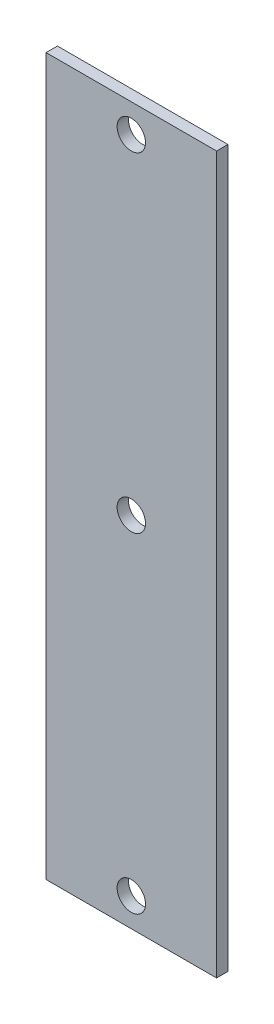
from build123d import *

# Parameters (mm, degrees)
SKETCH1_W           = 30
SKETCH1_H           = 126
SKETCH1_R           = 2.5
BOSS_EXTRUDE1_DEPTH = 2


with BuildPart() as part:
    # Sketch1 → Boss-Extrude1 (new body)
    with BuildSketch(Plane.XY):
        Rectangle(SKETCH1_W, SKETCH1_H)
        with Locations((0, 58)):
            Circle(SKETCH1_R, mode=Mode.SUBTRACT)
        with Locations((0, -58)):
            Circle(SKETCH1_R, mode=Mode.SUBTRACT)
        Circle(SKETCH1_R, mode=Mode.SUBTRACT)
    extrude(amount=BOSS_EXTRUDE1_DEPTH)


solid = part.part
